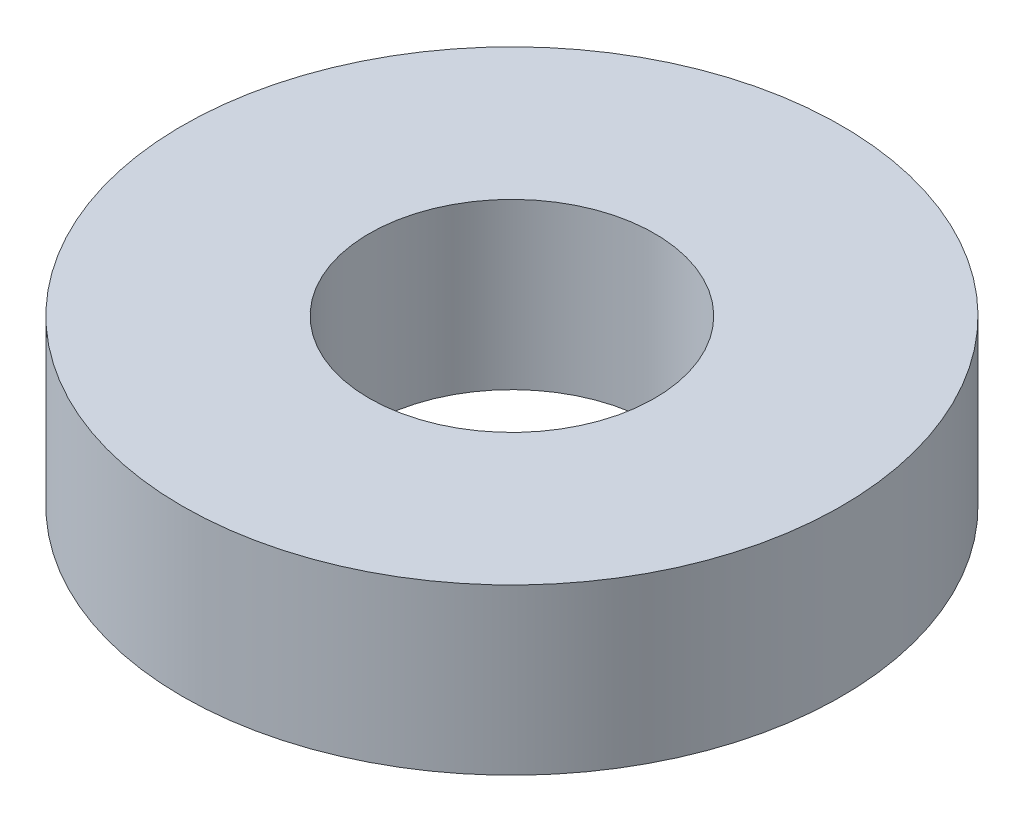
from build123d import *

# Parameters (mm, degrees)
SKETCH1_R           = 25.4
BOSS_EXTRUDE1_DEPTH = 12.7
SKETCH4_R           = 11
CUT_EXTRUDE3_DEPTH  = 60


with BuildPart() as part:
    # Sketch1 → Boss-Extrude1 (new body)
    with BuildSketch(Plane(origin=(0, 0, 0), x_dir=(1, 0, 0), z_dir=(0, 1, 0))):
        Circle(SKETCH1_R)
    extrude(amount=BOSS_EXTRUDE1_DEPTH)

    # Sketch4 → Cut-Extrude3 (cut)
    with BuildSketch(Plane(origin=(0, 12.7, 0), x_dir=(1, 0, 0), z_dir=(0, 1, 0))):
        Circle(SKETCH4_R)
    extrude(amount=-CUT_EXTRUDE3_DEPTH, mode=Mode.SUBTRACT)


solid = part.part
